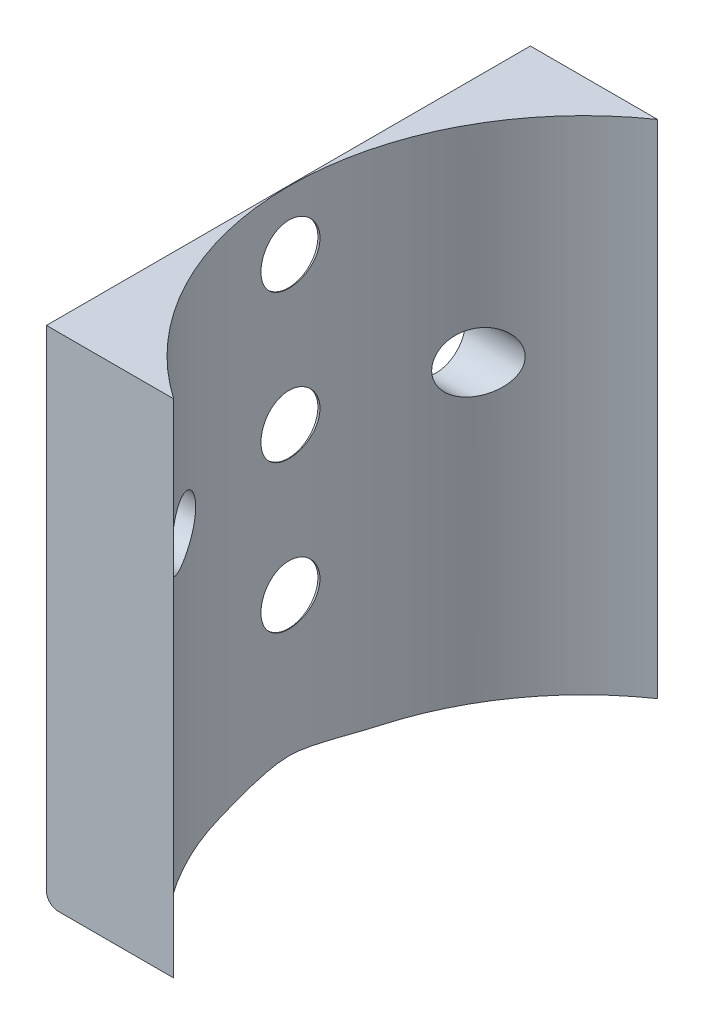
from build123d import *

# Parameters (mm, degrees)
SKETCH_1_W          = 25
SKETCH_1_H          = 41
EXTRUDE_1_DEPTH     = 42.5
FILLET_1_R          = 1
SKETCH_2_R          = 24.95
CUT_EXTRUDE_1_DEPTH = 42.5
SKETCH_3_R          = 2.5
CUT_EXTRUDE_2_DEPTH = 10


with BuildPart() as part:
    # Эскиз1 → Бобышка-Вытянуть1 (new body)
    with BuildSketch(Plane(origin=(0, 0, 0), x_dir=(1, 0, 0), z_dir=(0, 1, 0))):
        Rectangle(SKETCH_1_W, SKETCH_1_H)
    extrude(amount=EXTRUDE_1_DEPTH)

    # Скругление1
    fillet_1_edges = [part.edges().sort_by_distance(p)[0] for p in [
        (-12.5, 0, 0),
    ]]
    fillet(fillet_1_edges, radius=FILLET_1_R)

    # Эскиз2 → Вырез-Вытянуть1 (cut)
    with BuildSketch(Plane(origin=(0, 42.5, 0), x_dir=(1, 0, 0), z_dir=(0, 1, 0))):
        with Locations((12.5, 0)):
            Circle(SKETCH_2_R)
    extrude(amount=-CUT_EXTRUDE_1_DEPTH, mode=Mode.SUBTRACT)

    # Эскиз3 → Вырез-Вытянуть2 (cut)
    with BuildSketch(Plane.ZY.offset(12.5)):
        with Locations((-12.5, 25)):
            Circle(SKETCH_3_R)
        with Locations((0, 37.5)):
            Circle(SKETCH_3_R)
        with Locations((12.5, 25)):
            Circle(SKETCH_3_R)
        with Locations((0, 12.5)):
            Circle(SKETCH_3_R)
        with Locations((0, 25)):
            Circle(SKETCH_3_R)
    extrude(amount=-CUT_EXTRUDE_2_DEPTH, mode=Mode.SUBTRACT)


solid = part.part
